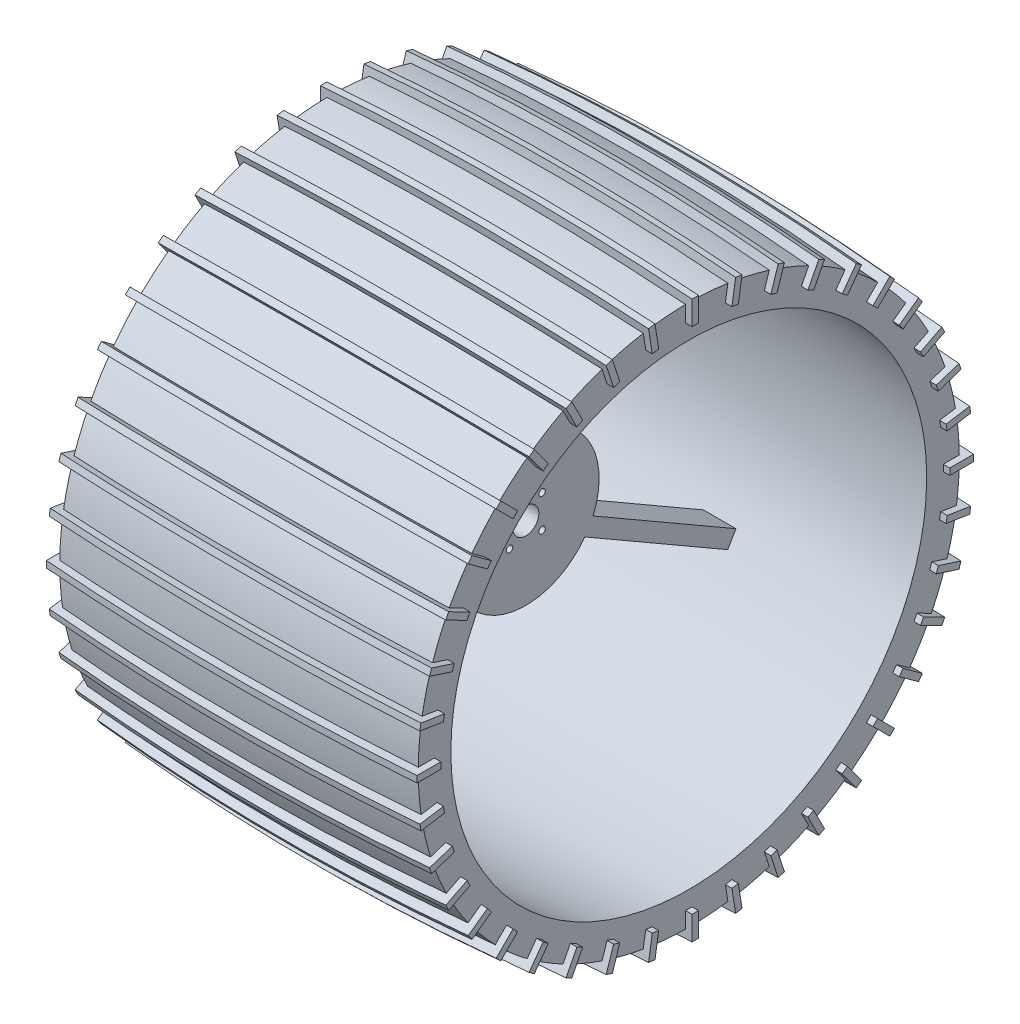
from build123d import *

# Parameters (mm, degrees)
SALIENTE_EXTRUIR6_DEPTH = 1
MATRIZC1_COUNT          = 40
CROQUIS9_R              = 22.5
CROQUIS9_R_2            = 4
SALIENTE_EXTRUIR7_DEPTH = 5
SALIENTE_EXTRUIR8_DEPTH = 5
MATRIZC2_COUNT          = 3
CROQUIS13_R             = 1
CORTAR_EXTRUIR3_DEPTH   = 15


with BuildPart() as part:
    # Croquis2 → Revolución1 (revolve)
    with BuildSketch(Plane.XY):
        with BuildLine():
            Line((-55, 73), (-55, 83))
            ThreePointArc((-55, 83), (0, 85), (55, 83))
            Line((55, 83), (55, 73))
            ThreePointArc((55, 73), (0, 75), (-55, 73))
        make_face()
    revolve(axis=Axis((-55, 0, 0), (1, 0, 0)))

    # Croquis5 → Saliente-Extruir6 (add, symmetric)
    with BuildSketch(Plane.XY):
        with BuildLine():
            Line((57, 85.399901065), (57, 78.075771835))
            Line((57, 78.075771835), (-57, 78.075771835))
            Line((-57, 78.075771835), (-57, 85.106689935))
            ThreePointArc((-57, 85.106689935), (-0.005524442, 87.401189491), (57, 85.399901065))
        make_face()
    saliente_extruir6 = extrude(amount=SALIENTE_EXTRUIR6_DEPTH, both=True)

    # MatrizC1: Saliente-Extruir6 ×40 about axis
    matrizc1_axis = Axis((0, 0, 0), (1, 0, 0))
    for i in range(1, MATRIZC1_COUNT):
        add(saliente_extruir6.rotate(matrizc1_axis, i * 360 / MATRIZC1_COUNT))


with BuildPart() as body_2:
    # Croquis9 → Saliente-Extruir7 (new body, symmetric)
    with BuildSketch(Plane(origin=(0, 0, 0), x_dir=(0, 0, -1), z_dir=(1, 0, 0))):
        Circle(CROQUIS9_R)
        Circle(CROQUIS9_R_2, mode=Mode.SUBTRACT)
    extrude(amount=SALIENTE_EXTRUIR7_DEPTH, both=True)

    # Croquis11 → Saliente-Extruir8 (add, symmetric)
    with BuildSketch(Plane(origin=(0, 0, 0), x_dir=(0, 0, -1), z_dir=(1, 0, 0))):
        Polygon((2.5, 73), (-2.5, 73), (-2.5, 17.798718411), (0, 17.798718411), (2.5, 17.798718411), align=None)
    saliente_extruir8 = extrude(amount=SALIENTE_EXTRUIR8_DEPTH, both=True)

    # MatrizC2: Saliente-Extruir8 ×3 about axis
    matrizc2_axis = Axis((0, 0, 0), (1, 0, 0))
    for i in range(1, MATRIZC2_COUNT):
        add(saliente_extruir8.rotate(matrizc2_axis, i * 360 / MATRIZC2_COUNT))

    # Croquis13 → Cortar-Extruir3 (cut)
    with BuildSketch(Plane(origin=(5, 0, 0), x_dir=(0, 0, -1), z_dir=(1, 0, 0))):
        with Locations((-5, 5)):
            Circle(CROQUIS13_R)
        with Locations((5, 5)):
            Circle(CROQUIS13_R)
        with Locations((5, -5)):
            Circle(CROQUIS13_R)
        with Locations((-5, -5)):
            Circle(CROQUIS13_R)
    extrude(amount=-CORTAR_EXTRUIR3_DEPTH, mode=Mode.SUBTRACT)


solid = Compound([part.part, body_2.part])
